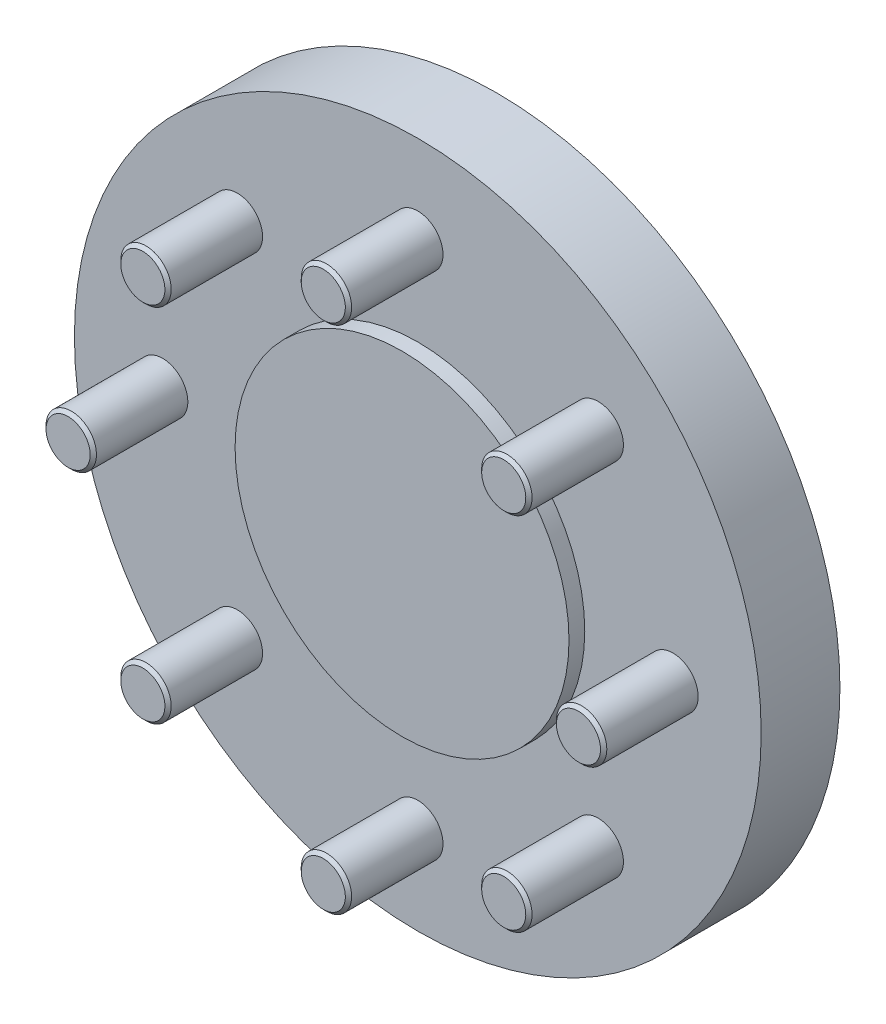
from build123d import *

# Parameters (mm, degrees)
SKETCH2_R                    = 8
BOSS_EXTRUDE1_DEPTH          = 30
CHAMFER1_SIZE                = 1
CIRPATTERN1_COUNT            = 8
CHAMFER1_OF_CIRPATTERN1_SIZE = 1


with BuildPart() as part:
    # Sketch1 → Revolve1 (revolve)
    with BuildSketch(Plane(origin=(0, 0, 0), x_dir=(1, 0, 0), z_dir=(0, 1, 0))):
        Polygon((0, 0), (0, 75), (30, 75), (30, 30), (109, 30), (109, 5), (53, 5), (53, 0), align=None)
    revolve(axis=Axis((0, 0, 0), (0, 0, -1)))

    # Sketch2 → Boss-Extrude1 (add)
    with BuildSketch(Plane.XY.offset(-5)):
        with Locations((81, 0)):
            Circle(SKETCH2_R)
    boss_extrude1 = extrude(amount=BOSS_EXTRUDE1_DEPTH)

    # Chamfer1
    chamfer1_edges = [part.edges().sort_by_distance(p)[0] for p in [
        (73, 0, 25),
    ]]
    chamfer(chamfer1_edges, length=CHAMFER1_SIZE)

    # CirPattern1: Boss-Extrude1 ×8 about axis
    cirpattern1_axis = Axis((0, 0, 0), (0, 0, 1))
    for i in range(1, CIRPATTERN1_COUNT):
        add(boss_extrude1.rotate(cirpattern1_axis, i * 360 / CIRPATTERN1_COUNT))

    # Chamfer1 of CirPattern1
    chamfer1_of_cirpattern1_edges = [part.edges().sort_by_distance(p)[0] for p in [
        (51.618795027, 51.618795027, 25),
        (0, 73, 25),
        (-51.618795027, 51.618795027, 25),
        (-73, 0, 25),
        (-51.618795027, -51.618795027, 25),
        (0, -73, 25),
        (51.618795027, -51.618795027, 25),
    ]]
    chamfer(chamfer1_of_cirpattern1_edges, length=CHAMFER1_OF_CIRPATTERN1_SIZE)


solid = part.part
